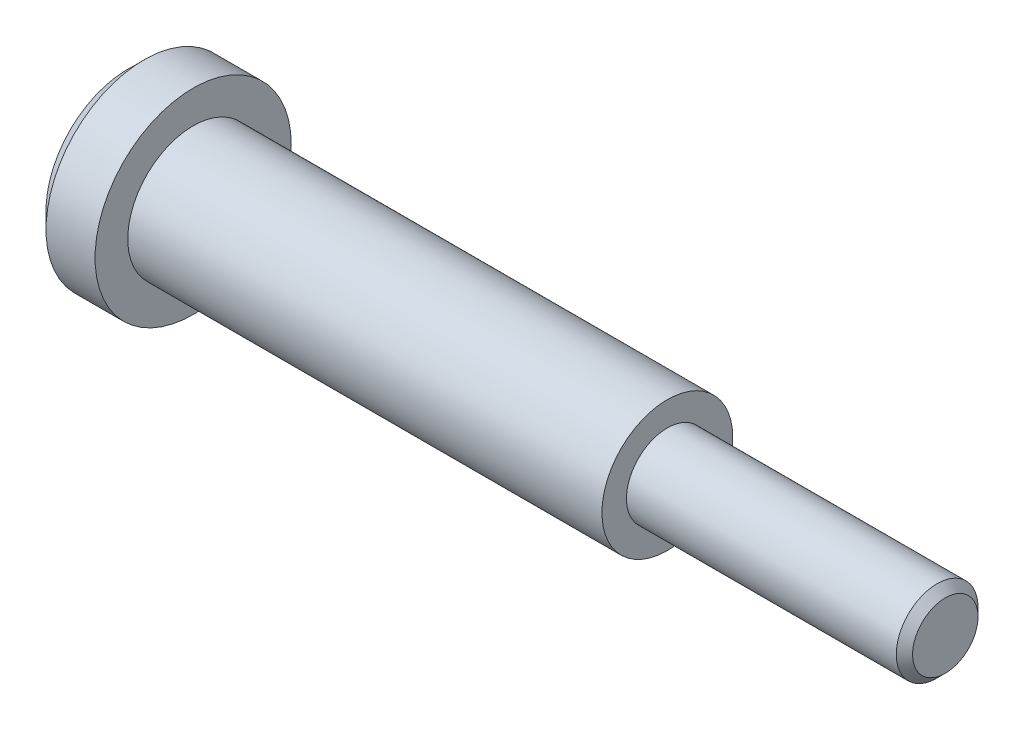
from build123d import *

# Parameters (mm, degrees)
SKETCH1_R           = 6
BOSS_EXTRUDE1_DEPTH = 4
SKETCH2_R           = 4
BOSS_EXTRUDE2_DEPTH = 29
SKETCH3_R           = 2.5
BOSS_EXTRUDE3_DEPTH = 17
CHAMFER1_SIZE       = 0.5
CHAMFER2_SIZE       = 1
SKETCH4_R           = 2.5
CUT_EXTRUDE1_DEPTH  = 1
FILLET1_R           = 0.5


with BuildPart() as part:
    # Sketch1 → Boss-Extrude1 (new body)
    with BuildSketch(Plane(origin=(0, 0, 0), x_dir=(0, 0, -1), z_dir=(1, 0, 0))):
        Circle(SKETCH1_R)
    extrude(amount=BOSS_EXTRUDE1_DEPTH)

    # Sketch2 → Boss-Extrude2 (add)
    with BuildSketch(Plane(origin=(4, 0, 0), x_dir=(0, 0, -1), z_dir=(1, 0, 0))):
        Circle(SKETCH2_R)
    extrude(amount=BOSS_EXTRUDE2_DEPTH)

    # Sketch3 → Boss-Extrude3 (add)
    with BuildSketch(Plane(origin=(33, 0, 0), x_dir=(0, 0, -1), z_dir=(1, 0, 0))):
        Circle(SKETCH3_R)
    extrude(amount=BOSS_EXTRUDE3_DEPTH)

    # Chamfer1
    chamfer1_edges = [part.edges().sort_by_distance(p)[0] for p in [
        (50, 0, 2.5),
    ]]
    chamfer(chamfer1_edges, length=CHAMFER1_SIZE)

    # Chamfer2
    chamfer2_edges = [part.edges().sort_by_distance(p)[0] for p in [
        (0, 0, 6),
    ]]
    chamfer(chamfer2_edges, length=CHAMFER2_SIZE)

    # Sketch4 → Cut-Extrude1 (cut)
    with BuildSketch(Plane.ZY):
        Circle(SKETCH4_R)
    extrude(amount=-CUT_EXTRUDE1_DEPTH, mode=Mode.SUBTRACT)

    # Fillet1
    fillet1_edges = [part.edges().sort_by_distance(p)[0] for p in [
        (0, 0, -2.5),
    ]]
    fillet(fillet1_edges, radius=FILLET1_R)


solid = part.part
